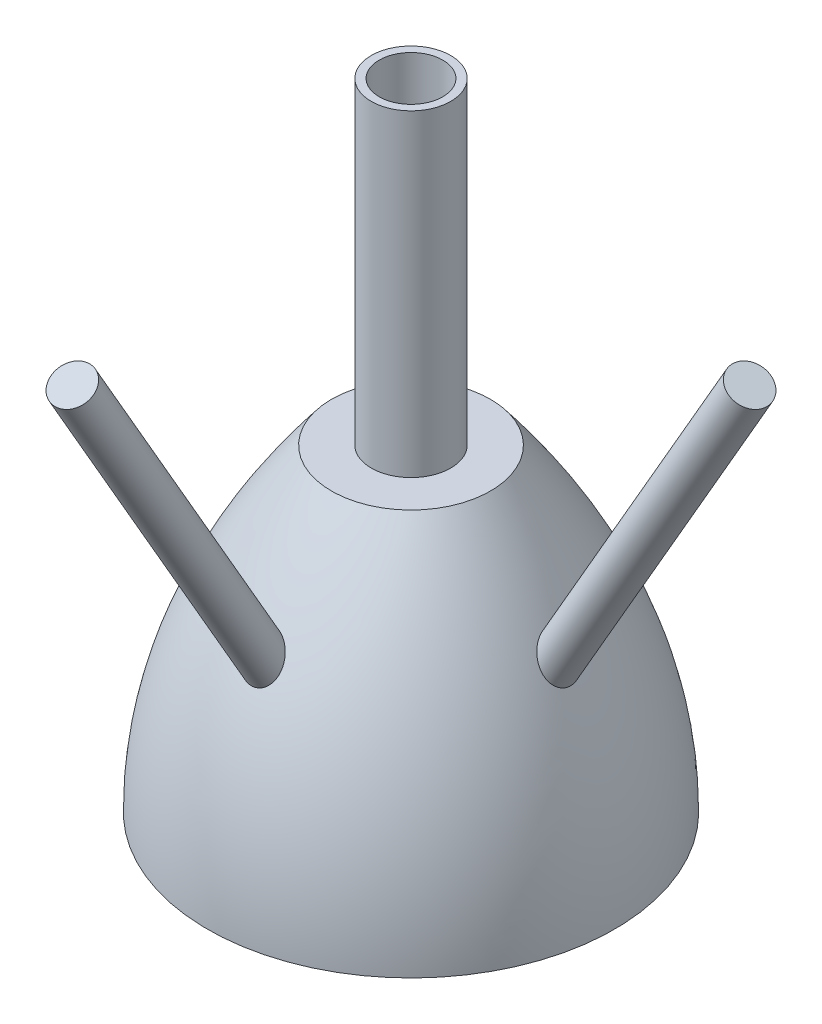
from build123d import *

# Parameters (mm, degrees)
SHELL1_T            = -50.8
SKETCH2_R           = 126.999999999
BOSS_EXTRUDE1_DEPTH = 1014.6920778
SKETCH8_R           = 50.799999999
CUT_EXTRUDE1_DEPTH  = 989.2920778
CUT_EXTRUDE2_REACH  = 1409.222
SKETCH9_R           = 101.6
FILLET2_R           = 127
BOSS_EXTRUDE4_REACH = 2510.949
SKETCH5_R           = 63.5
CIRPATTERN1_COUNT   = 2
CIRPATTERN1_ANGLE   = 90


with BuildPart() as part:
    # Sketch1 → Revolve1 (revolve)
    with BuildSketch(Plane.XY):
        with BuildLine():
            Line((0, 0), (650, 0))
            add(Edge.make_bspline(
                [(650, 0), (650, 507.346035759), (254, 1014.692071517)],
                knots=[0, 0, 0, 1, 1, 1], degree=2))
            Line((254, 1014.692071517), (0, 1014.692071517))
            Line((0, 1014.692071517), (0, 0))
        make_face()
    revolve(axis=Axis((0, 1014.692071517, 0), (0, -1, 0)))

    # Shell1
    shell1_openings = [part.faces().sort_by_distance(p)[0] for p in [
        (0, 0, 0),
    ]]
    offset(amount=SHELL1_T, openings=shell1_openings, kind=Kind.INTERSECTION)

    # Sketch2 → Boss-Extrude1 (add)
    with BuildSketch(Plane(origin=(0, 1014.692071518, 0), x_dir=(1, 0, 0), z_dir=(0, 1, 0))):
        with Locations(Location((0, 0, 0), (0, 0, 180))):
            Circle(SKETCH2_R)
    extrude(amount=BOSS_EXTRUDE1_DEPTH)

    # Sketch8 → Cut-Extrude1 (cut)
    with BuildSketch(Plane(origin=(0, 2029.384149318, 0), x_dir=(1, 0, 0), z_dir=(0, 1, 0))):
        with Locations(Location((0, 0, 0), (0, 0, 180))):
            Circle(SKETCH8_R)
    extrude(amount=-CUT_EXTRUDE1_DEPTH, mode=Mode.SUBTRACT)

    # Sketch9 → Cut-Extrude2 (cut, up to next)
    with BuildSketch(Plane.XZ.offset(-963.892071518), mode=Mode.PRIVATE) as cut_extrude2_sk1:
        Circle(SKETCH9_R)
    cut_extrude2_tool1 = extrude(cut_extrude2_sk1.sketch, amount=-CUT_EXTRUDE2_REACH, mode=Mode.PRIVATE) & part.part
    add(cut_extrude2_tool1.solids().sort_by_distance((0, 963.892072, 0))[0], mode=Mode.SUBTRACT)

    # Fillet2
    fillet2_edges = [part.edges().sort_by_distance(p)[0] for p in [
        (-229.058684879, 963.892071517, 8.8e-08),
    ]]
    fillet(fillet2_edges, radius=FILLET2_R)

    # Sketch5 → Boss-Extrude4 (add, up to next)
    with BuildSketch(Plane(origin=(0.000183349, 1759.76362049, 1016), x_dir=(0, 0.49999999999999495, -0.8660254037844416), z_dir=(9.023101202455188e-08, 0.866025403784438, 0.4999999999999929)), mode=Mode.PRIVATE) as boss_extrude4_sk1:
        with Locations(Location((-76.2, 0, 0), (0, 0, 180))):
            Circle(SKETCH5_R)
    boss_extrude4_tool1 = extrude(boss_extrude4_sk1.sketch, amount=-BOSS_EXTRUDE4_REACH, mode=Mode.PRIVATE) - part.part
    boss_extrude4 = boss_extrude4_tool1.solids().sort_by_distance((0.000183, 1721.66362, 1081.991136))[0]
    add(boss_extrude4)

    # CirPattern1: Boss-Extrude4 ×2 about axis
    cirpattern1_axis = Axis((0, 2029.384149318, 0), (0, 1, 0))
    for i in range(1, CIRPATTERN1_COUNT):
        add(boss_extrude4.rotate(cirpattern1_axis, i * CIRPATTERN1_ANGLE / (CIRPATTERN1_COUNT - 1)))


solid = part.part
